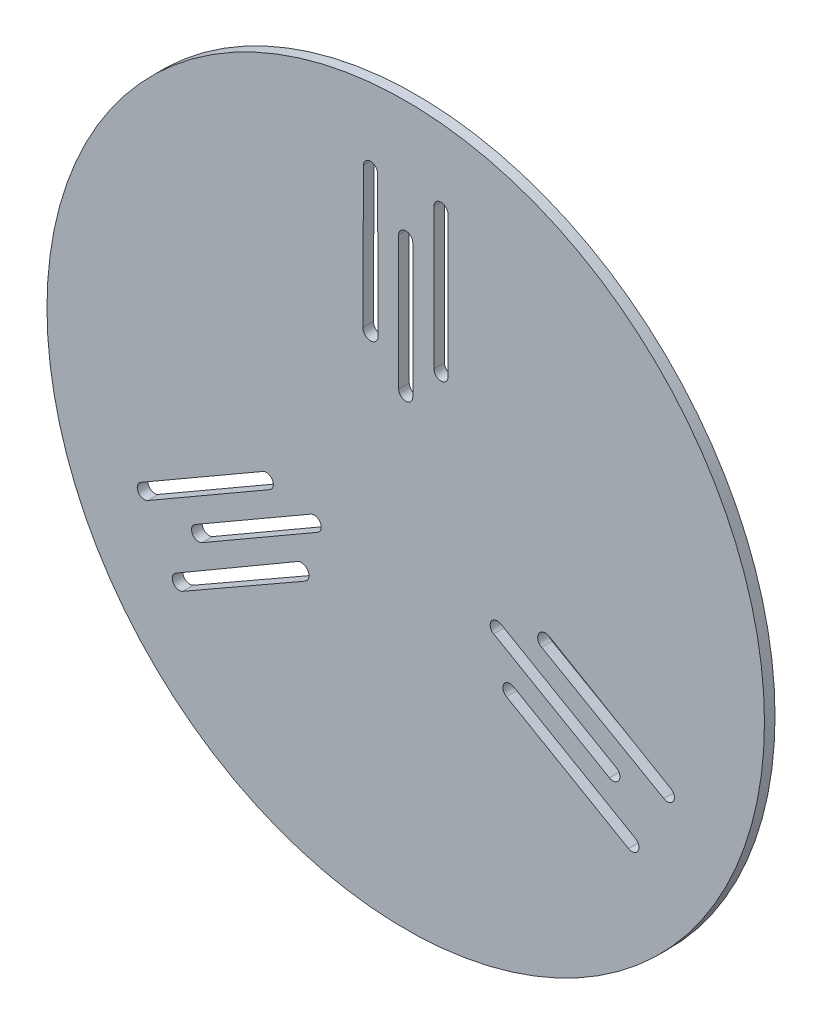
from build123d import *

# Parameters (mm, degrees)
SKETCH1_R           = 101.859163579
BOSS_EXTRUDE1_DEPTH = 3


with BuildPart() as part:
    # Sketch1 → Boss-Extrude1 (new body)
    with BuildSketch(Plane.XY):
        Circle(SKETCH1_R)
        with BuildLine():
            Line((-38.589791853, -13.042222407), (-73.230808005, -33.042222407))
            ThreePointArc((-73.230808005, -33.042222407), (-75.962858812, -32.3101716), (-75.230808005, -29.578120792))
            Line((-75.230808005, -29.578120792), (-40.589791853, -9.578120792))
            ThreePointArc((-40.589791853, -9.578120792), (-37.857741046, -10.3101716), (-38.589791853, -13.042222407))
        make_face(mode=Mode.SUBTRACT)
        with BuildLine():
            Line((-28.573863011, -30.544431757), (-63.282032303, -50.392304845))
            ThreePointArc((-63.282032303, -50.392304845), (-66.01408311, -49.660254038), (-65.282032303, -46.92820323))
            Line((-65.282032303, -46.92820323), (-30.739185351, -26.793983449))
            Line((-30.739185351, -26.793983449), (-30.723714344, -26.78496576))
            ThreePointArc((-30.723714344, -26.78496576), (-27.765727873, -27.577555846), (-28.558317959, -30.535542316))
            Line((-28.558317959, -30.535542316), (-28.573863011, -30.544431757))
        make_face(mode=Mode.SUBTRACT)
        with BuildLine():
            Line((-24.980762114, -16.732050808), (-57.812135025, -35.687252796))
            ThreePointArc((-57.812135025, -35.687252796), (-60.544185832, -34.955201988), (-59.812135025, -32.223151181))
            Line((-59.812135025, -32.223151181), (-26.980762114, -13.267949192))
            ThreePointArc((-26.980762114, -13.267949192), (-24.248711306, -14), (-24.980762114, -16.732050808))
        make_face(mode=Mode.SUBTRACT)
        with BuildLine():
            Line((30.589791853, -26.898628868), (65.230808005, -46.898628868))
            ThreePointArc((65.230808005, -46.898628868), (65.962858812, -49.630679675), (63.230808005, -50.362730483))
            Line((63.230808005, -50.362730483), (28.589791853, -30.362730483))
            ThreePointArc((28.589791853, -30.362730483), (27.857741046, -27.630679675), (30.589791853, -26.898628868))
        make_face(mode=Mode.SUBTRACT)
        with BuildLine():
            Line((26.980762114, -13.267949192), (59.812135025, -32.223151181))
            ThreePointArc((59.812135025, -32.223151181), (60.544185832, -34.955201988), (57.812135025, -35.687252796))
            Line((57.812135025, -35.687252796), (24.980762114, -16.732050808))
            ThreePointArc((24.980762114, -16.732050808), (24.248711306, -14), (26.980762114, -13.267949192))
        make_face(mode=Mode.SUBTRACT)
        with BuildLine():
            Line((40.739185351, -9.473475374), (75.282032303, -29.607695155))
            ThreePointArc((75.282032303, -29.607695155), (76.01408311, -32.339745962), (73.282032303, -33.07179677))
            Line((73.282032303, -33.07179677), (38.573863011, -13.223923681))
            Line((38.573863011, -13.223923681), (38.558317959, -13.21503424))
            ThreePointArc((38.558317959, -13.21503424), (37.765727873, -10.25704777), (40.723714344, -9.464457684))
            Line((40.723714344, -9.464457684), (40.739185351, -9.473475374))
        make_face(mode=Mode.SUBTRACT)
        with BuildLine():
            Line((-2, 30), (-2, 67.910403976))
            ThreePointArc((-2, 67.910403976), (0, 69.910403976), (2, 67.910403976))
            Line((2, 67.910403976), (2, 30))
            ThreePointArc((2, 30), (0, 28), (-2, 30))
        make_face(mode=Mode.SUBTRACT)
        with BuildLine():
            Line((-12.16532234, 40.01790713), (-12, 80))
            ThreePointArc((-12, 80), (-10, 82), (-8, 80))
            Line((-8, 80), (-7.83467766, 40.01790713))
            Line((-7.83467766, 40.01790713), (-7.834603616, 40))
            ThreePointArc((-7.834603616, 40), (-10, 37.834603616), (-12.165396384, 40))
            Line((-12.165396384, 40), (-12.16532234, 40.01790713))
        make_face(mode=Mode.SUBTRACT)
        with BuildLine():
            Line((8, 39.940851275), (8, 79.940851275))
            ThreePointArc((8, 79.940851275), (10, 81.940851275), (12, 79.940851275))
            Line((12, 79.940851275), (12, 39.940851275))
            ThreePointArc((12, 39.940851275), (10, 37.940851275), (8, 39.940851275))
        make_face(mode=Mode.SUBTRACT)
    extrude(amount=BOSS_EXTRUDE1_DEPTH)


solid = part.part
